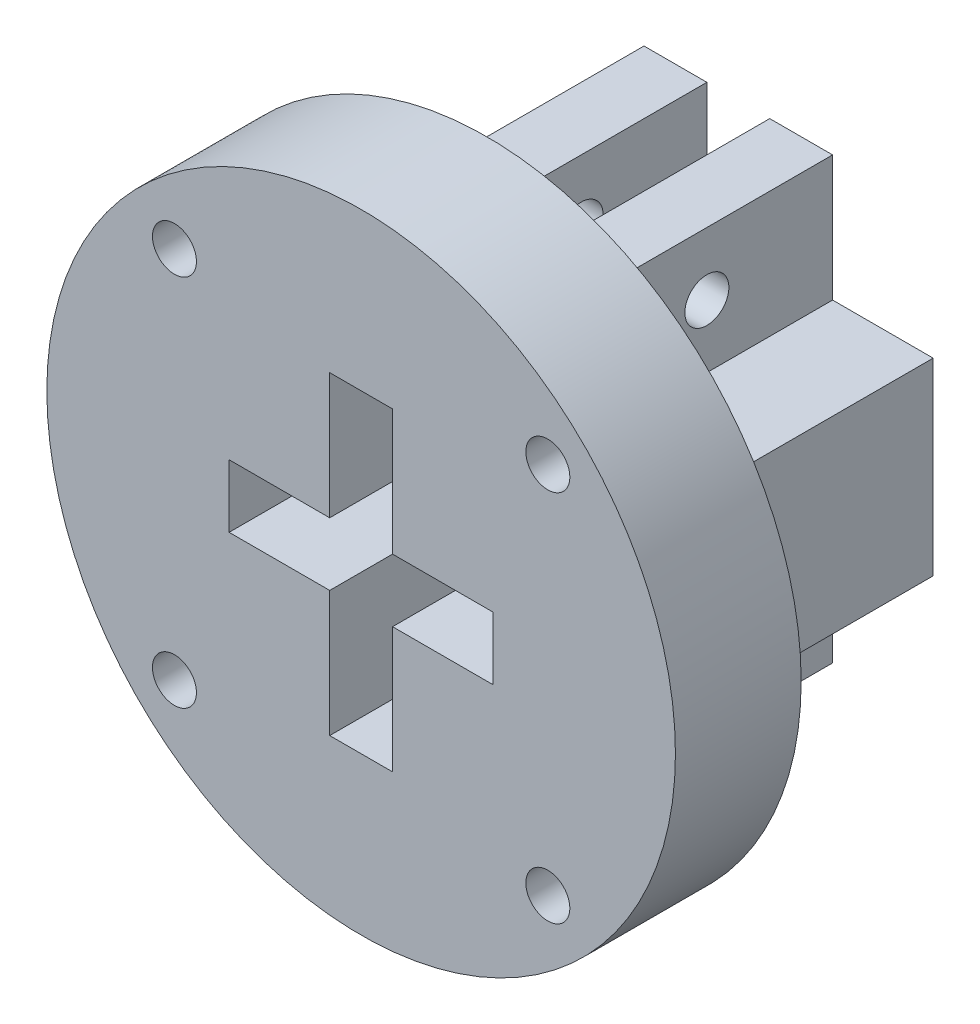
from build123d import *

# Parameters (mm, degrees)
EXTRUDE_1_DEPTH     = 20
SKETCH_2_R          = 25
EXTRUDE_2_DEPTH     = 10
SKETCH_5_W          = 5
SKETCH_5_H          = 5
CUT_EXTRUDE_2_DEPTH = 20
SKETCH_6_R          = 1.75
CUT_EXTRUDE_3_DEPTH = 10
SKETCH_7_R          = 1.75
CUT_EXTRUDE_4_DEPTH = 38


with BuildPart() as part:
    # 草图1 → 凸台-拉伸1 (new body)
    with BuildSketch(Plane.XY):
        Polygon((-15.5, 7.5), (-15.5, -7.5), (-7.5, -7.5), (-7.5, -17.5), (7.5, -17.5), (7.5, -7.5), (15.5, -7.5), (15.5, 7.5), (7.5, 7.5), (7.5, 17.5), (-7.5, 17.5), (-7.5, 7.5), align=None)
        Polygon((-10.5, 2.5), (-2.5, 2.5), (-2.5, 12.5), (2.5, 12.5), (2.5, 2.5), (10.5, 2.5), (10.5, -2.5), (2.5, -2.5), (2.5, -12.5), (-2.5, -12.5), (-2.5, -2.5), (-10.5, -2.5), align=None, mode=Mode.SUBTRACT)
    extrude(amount=EXTRUDE_1_DEPTH)

    # 草图2 → 凸台-拉伸2 (add)
    with BuildSketch(Plane.XY.offset(20)):
        Circle(SKETCH_2_R)
        Polygon((-10.5, -2.5), (-2.5, -2.5), (-2.5, -12.5), (2.5, -12.5), (2.5, -2.5), (10.5, -2.5), (10.5, 2.5), (2.5, 2.5), (2.5, 12.5), (-2.5, 12.5), (-2.5, 2.5), (-10.5, 2.5), align=None, mode=Mode.SUBTRACT)
    extrude(amount=EXTRUDE_2_DEPTH)

    # 草图5 → 切除-拉伸2 (cut)
    with BuildSketch(Plane(origin=(0, 0, 0), x_dir=(-1, 0, 0), z_dir=(0, 0, -1))):
        with Locations((0, 15)):
            Rectangle(SKETCH_5_W, SKETCH_5_H)
        with Locations((0, -15)):
            Rectangle(SKETCH_5_W, SKETCH_5_H)
    extrude(amount=-CUT_EXTRUDE_2_DEPTH, mode=Mode.SUBTRACT)

    # 草图6 → 切除-拉伸3 (cut)
    with BuildSketch(Plane(origin=(0, 0, 20), x_dir=(-1, 0, 0), z_dir=(0, 0, -1))):
        with Locations((14.849242405, 14.849242405)):
            Circle(SKETCH_6_R)
        with Locations((14.849242405, -14.849242405)):
            Circle(SKETCH_6_R)
        with Locations((-14.849242405, -14.849242405)):
            Circle(SKETCH_6_R)
        with Locations((-14.849242405, 14.849242405)):
            Circle(SKETCH_6_R)
    extrude(amount=-CUT_EXTRUDE_3_DEPTH, mode=Mode.SUBTRACT)

    # 草图7 → 切除-拉伸4 (cut)
    with BuildSketch(Plane.ZY.offset(7.5)):
        with Locations((10, 12.5)):
            Circle(SKETCH_7_R)
        with Locations((10, -12.5)):
            Circle(SKETCH_7_R)
    extrude(amount=-CUT_EXTRUDE_4_DEPTH, mode=Mode.SUBTRACT)


solid = part.part
